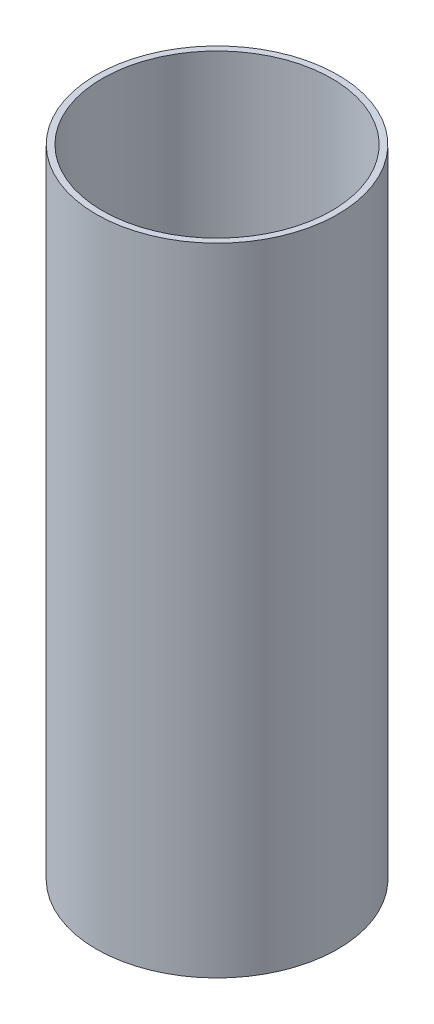
from build123d import *

# Parameters (mm, degrees)
SKETCH1_R           = 93.6625
SKETCH1_R_2         = 88.9
BOSS_EXTRUDE1_DEPTH = 246.71401


with BuildPart() as part:
    # Sketch1 → Boss-Extrude1 (new body, symmetric)
    with BuildSketch(Plane(origin=(0, 0, 0), x_dir=(1, 0, 0), z_dir=(0, 1, 0))):
        Circle(SKETCH1_R)
        Circle(SKETCH1_R_2, mode=Mode.SUBTRACT)
    extrude(amount=BOSS_EXTRUDE1_DEPTH, both=True)


solid = part.part
